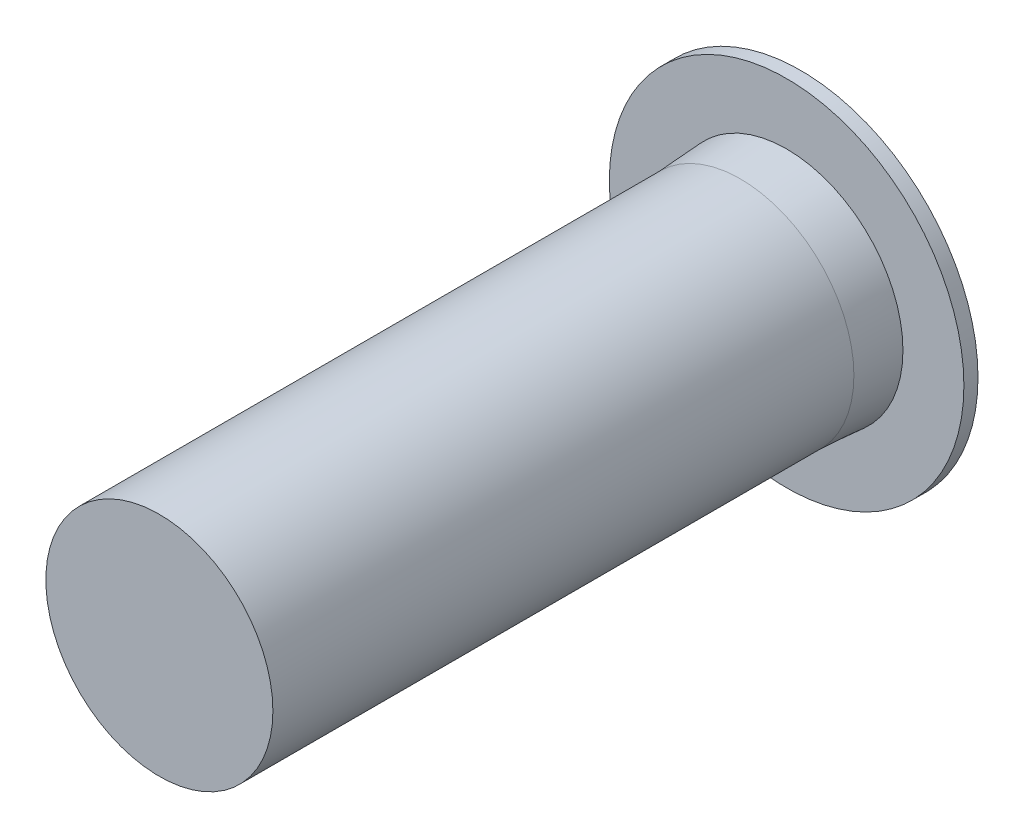
from build123d import *

# Parameters (mm, degrees)
SKETCH2_R           = 5.475
SKETCH1_R           = 5.61
SKETCH3_R           = 5.475
SKETCH2_2_R         = 5.475
SKETCH4_R           = 8.55
BOSS_EXTRUDE1_DEPTH = 0.68
SKETCH5_R           = 4.92
CUT_EXTRUDE1_DEPTH  = 16.57


with BuildPart() as part:
    # Sketch2 → Loft1 section 0
    with BuildSketch(Plane.XY.offset(2.23)):
        Circle(SKETCH2_R)
    # Sketch1 → Loft1 section 1
    with BuildSketch(Plane.XY):
        Circle(SKETCH1_R)
    loft()

    # Sketch3 → Loft2 section 0
    with BuildSketch(Plane.XY.offset(30.25)):
        Circle(SKETCH3_R)
    # Sketch2_2 → Loft2 section 1
    with BuildSketch(Plane.XY.offset(2.23)):
        Circle(SKETCH2_2_R)
    loft()

    # Sketch4 → Boss-Extrude1 (add)
    with BuildSketch(Plane(origin=(0, 0, 0), x_dir=(-1, 0, 0), z_dir=(0, 0, -1))):
        Circle(SKETCH4_R)
    extrude(amount=BOSS_EXTRUDE1_DEPTH)

    # Sketch5 → Cut-Extrude1 (cut)
    with BuildSketch(Plane(origin=(0, 0, -0.68), x_dir=(-1, 0, 0), z_dir=(0, 0, -1))):
        Circle(SKETCH5_R)
    extrude(amount=-CUT_EXTRUDE1_DEPTH, mode=Mode.SUBTRACT)


solid = part.part
